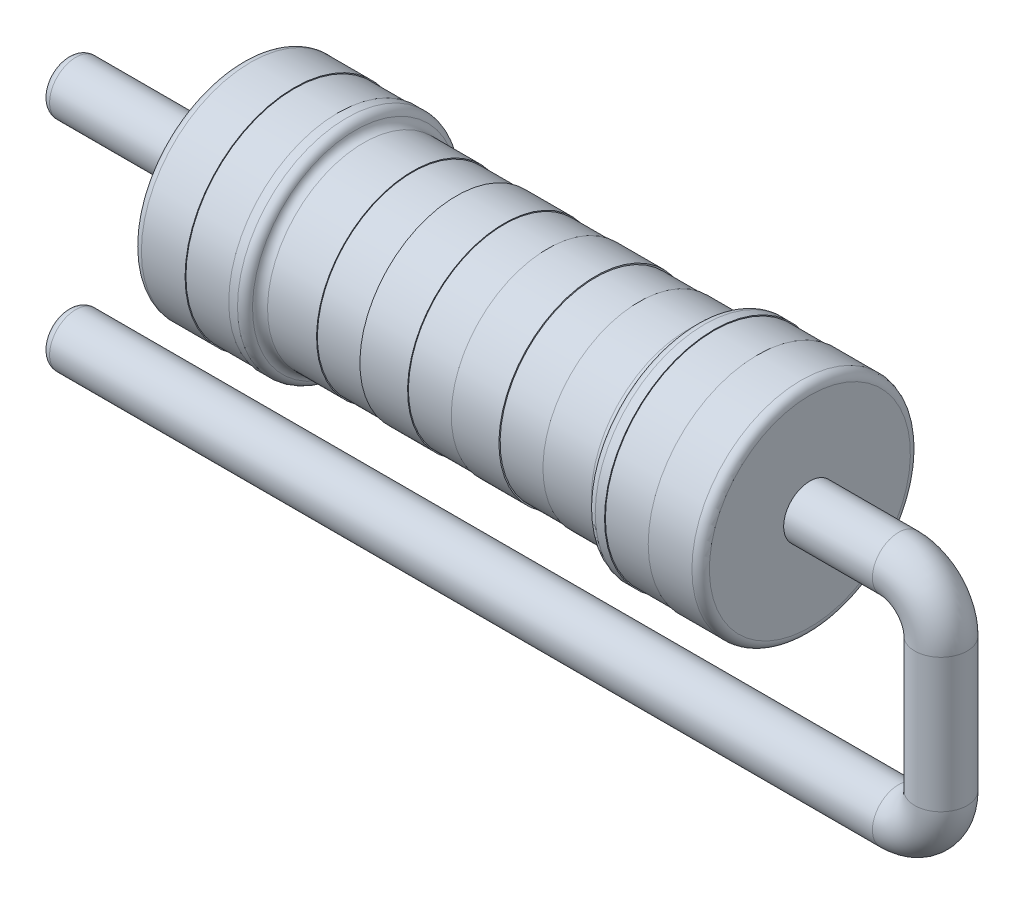
from build123d import *

# Parameters (mm, degrees)
FILLET3_R = 0.1
FILLET4_R = 0.1
FILLET5_R = 0.1
SKETCH3_R = 0.3
SKETCH4_R = 0.3
FILLET7_R = 0.1


with BuildPart() as part:
    # Sketch1 → Revolve3 (revolve)
    with BuildSketch(Plane.XY):
        Polygon((-3.25, 0), (3.25, 0), (3.25, -1.25), (2.65, -1.25), (2.65, -1.24), (2.15, -1.24), (2.15, -1.25), (1.95, -1.25), (1.95, -1.1), (1.295523437, -1.1), (1.295523437, -1.09), (0.795523437, -1.09), (0.795523437, -1.1037537), (0.25, -1.1037537), (0.25, -1.0937537), (-0.25, -1.0937537), (-0.25, -1.1037537), (-0.795523437, -1.1037537), (-0.795523437, -1.09), (-1.295523437, -1.09), (-1.295523437, -1.1), (-1.95, -1.1), (-1.95, -1.25), (-2.15, -1.25), (-2.15, -1.24), (-2.65, -1.24), (-2.65, -1.25), (-3.25, -1.25), align=None)
    revolve(axis=Axis((-3.25, 0, 0), (1, 0, 0)))

    # Fillet3
    fillet3_edges = [part.edges().sort_by_distance(p)[0] for p in [
        (-3.25, 1.25, 0),
        (1.95, 1.1, 0),
    ]]
    fillet(fillet3_edges, radius=FILLET3_R)

    # Fillet4
    fillet4_edges = [part.edges().sort_by_distance(p)[0] for p in [
        (1.95, 1.25, 0),
        (-1.95, 1.25, 0),
    ]]
    fillet(fillet4_edges, radius=FILLET4_R)

    # Fillet5
    fillet5_edges = [part.edges().sort_by_distance(p)[0] for p in [
        (-1.95, 1.1, 0),
        (3.25, 1.25, 0),
    ]]
    fillet(fillet5_edges, radius=FILLET5_R)

    # Sweep2: sweep along a curve in space
    with BuildLine() as sweep2_path:
        Line((3.25, 0, 0), (4.265587077, 0, 0))
        ThreePointArc((4.75, -0.484412923, 0), (4.60811874, -0.14188126, 0), (4.265587077, 0, 0))
        Line((4.75, -0.484412923, 0), (4.75, -2.015587077, 0))
        ThreePointArc((4.265587077, -2.5, 0), (4.60811874, -2.35811874, 0), (4.75, -2.015587077, 0))
        Line((4.265587077, -2.5, 0), (-5.25, -2.5, 0))
    # Sketch3 → Sweep2 (sweep)
    with BuildSketch(Plane(origin=(3.25, 0, 0), x_dir=(0, 0, -1), z_dir=(1, 0, 0))):
        Circle(SKETCH3_R)
    sweep(path=sweep2_path.line)

    # Sweep3: sweep along a curve in space
    with BuildLine() as sweep3_path:
        Line((-3.25, 0, 0), (-5.25, 0, 0))
    # Sketch4 → Sweep3 (sweep)
    with BuildSketch(Plane.ZY.offset(3.25)):
        Circle(SKETCH4_R)
    sweep(path=sweep3_path.line)

    # Fillet7
    fillet7_edges = [part.edges().sort_by_distance(p)[0] for p in [
        (-5.25, -2.5, 0.3),
        (-5.25, 0, -0.3),
    ]]
    fillet(fillet7_edges, radius=FILLET7_R)


solid = part.part
